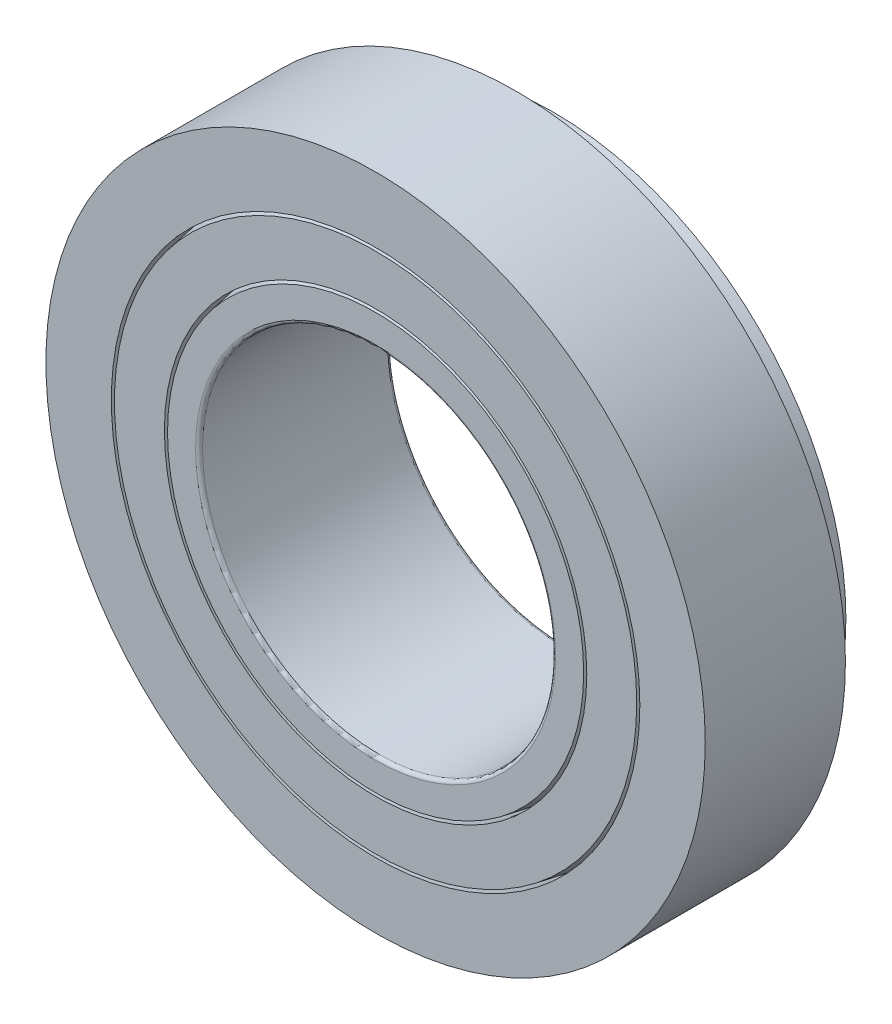
from build123d import *

# Parameters (mm, degrees)
CIRPATTERN1_COUNT = 10
CIRPATTERN2_COUNT = 10
CIRPATTERN2_ANGLE = 324
FILLET2_R         = 0.267890625


with BuildPart() as part:
    # Sketch1 → Revolve1 (revolve)
    with BuildSketch(Plane(origin=(0, 0, 0), x_dir=(0, 0, -1), z_dir=(1, 0, 0))):
        Polygon((-7.3421875, 25.2015625), (3.3734375, 25.2015625), (3.3734375, 22.090391303), (-7.3421875, 20.2009375), align=None)
    revolve(axis=Axis((0, 0, 7.3421875), (0, 0, -1)))


with BuildPart() as body_2:
    # Sketch5 → Revolve4 (revolve)
    with BuildSketch(Plane(origin=(0, 0, 0), x_dir=(0, 0, -1), z_dir=(1, 0, 0))):
        Polygon((7.3421875, 18.494375), (-7.3421875, 15.905123493), (-7.3421875, 13.49375), (7.3421875, 13.49375), align=None)
    revolve(axis=Axis((0, 0, 7.3421875), (0, 0, -1)))

    # Fillet2
    fillet2_edges = [body_2.edges().sort_by_distance(p)[0] for p in [
        (0, -13.49375, 7.3421875),
        (0, -13.49375, -7.3421875),
    ]]
    fillet(fillet2_edges, radius=FILLET2_R)


with BuildPart() as body_3:
    # Sketch2 → Revolve2 (revolve)
    with BuildSketch(Plane(origin=(0, 0, 0), x_dir=(0, 0, -1), z_dir=(1, 0, 0))):
        Polygon((-7.3421875, 19.961616999), (-7.3421875, 16.144443994), (3.3734375, 18.033897796), (6.904386284, 18.656499334), (6.251611255, 22.35857049), (3.3734375, 21.851070802), align=None)
    revolve(axis=Axis((0, 0, 7.3421875), (0, 0, -1)))

    # Sketch3 → Cut-Revolve1 (revolve, cut)
    with BuildSketch(Plane(origin=(0, 0, 0), x_dir=(0, 0, -1), z_dir=(1, 0, 0))):
        Polygon((-6.240246308, 18.24733246), (-6.607560039, 20.330472142), (3.006123769, 22.025623982), (3.3734375, 19.942484299), align=None)
    cut_revolve1 = revolve(axis=Axis((0, 18.053030496, 7.3421875), (0, 0.173648178, -0.984807753)), mode=Mode.SUBTRACT)

    # CirPattern1: Cut-Revolve1 ×10 about axis
    cirpattern1_axis = Axis((0, 0, 0), (0, 0, 1))
    for i in range(1, CIRPATTERN1_COUNT):
        add(cut_revolve1.rotate(cirpattern1_axis, i * 360 / CIRPATTERN1_COUNT), mode=Mode.SUBTRACT)


with BuildPart() as body_4:
    # Sketch4 → Revolve3 (revolve)
    with BuildSketch(Plane(origin=(0, 0, 0), x_dir=(0, 0, -1), z_dir=(1, 0, 0))):
        Polygon((-6.563453402, 20.080330973), (3.050230407, 21.775482812), (3.3734375, 19.942484299), (-6.240246308, 18.24733246), align=None)
    revolve(axis=Axis((0, 18.053030496, 7.3421875), (0, 0.173648178, -0.984807753)))


with BuildPart() as cirpattern2_1:
    # CirPattern2: pattern copy
    add(body_4.part.rotate(Axis((0, 0, -7.3421875), (0, 0, 1)), 1 * CIRPATTERN2_ANGLE / (CIRPATTERN2_COUNT - 1)))


with BuildPart() as cirpattern2_2:
    # CirPattern2: pattern copy
    add(body_4.part.rotate(Axis((0, 0, -7.3421875), (0, 0, 1)), 2 * CIRPATTERN2_ANGLE / (CIRPATTERN2_COUNT - 1)))


with BuildPart() as cirpattern2_3:
    # CirPattern2: pattern copy
    add(body_4.part.rotate(Axis((0, 0, -7.3421875), (0, 0, 1)), 3 * CIRPATTERN2_ANGLE / (CIRPATTERN2_COUNT - 1)))


with BuildPart() as cirpattern2_4:
    # CirPattern2: pattern copy
    add(body_4.part.rotate(Axis((0, 0, -7.3421875), (0, 0, 1)), 4 * CIRPATTERN2_ANGLE / (CIRPATTERN2_COUNT - 1)))


with BuildPart() as cirpattern2_5:
    # CirPattern2: pattern copy
    add(body_4.part.rotate(Axis((0, 0, -7.3421875), (0, 0, 1)), 5 * CIRPATTERN2_ANGLE / (CIRPATTERN2_COUNT - 1)))


with BuildPart() as cirpattern2_6:
    # CirPattern2: pattern copy
    add(body_4.part.rotate(Axis((0, 0, -7.3421875), (0, 0, 1)), 6 * CIRPATTERN2_ANGLE / (CIRPATTERN2_COUNT - 1)))


with BuildPart() as cirpattern2_7:
    # CirPattern2: pattern copy
    add(body_4.part.rotate(Axis((0, 0, -7.3421875), (0, 0, 1)), 7 * CIRPATTERN2_ANGLE / (CIRPATTERN2_COUNT - 1)))


with BuildPart() as cirpattern2_8:
    # CirPattern2: pattern copy
    add(body_4.part.rotate(Axis((0, 0, -7.3421875), (0, 0, 1)), 8 * CIRPATTERN2_ANGLE / (CIRPATTERN2_COUNT - 1)))


with BuildPart() as cirpattern2_9:
    # CirPattern2: pattern copy
    add(body_4.part.rotate(Axis((0, 0, -7.3421875), (0, 0, 1)), 9 * CIRPATTERN2_ANGLE / (CIRPATTERN2_COUNT - 1)))


solid = Compound([part.part, body_2.part, body_3.part, body_4.part, cirpattern2_1.part, cirpattern2_2.part, cirpattern2_3.part, cirpattern2_4.part, cirpattern2_5.part, cirpattern2_6.part, cirpattern2_7.part, cirpattern2_8.part, cirpattern2_9.part])
